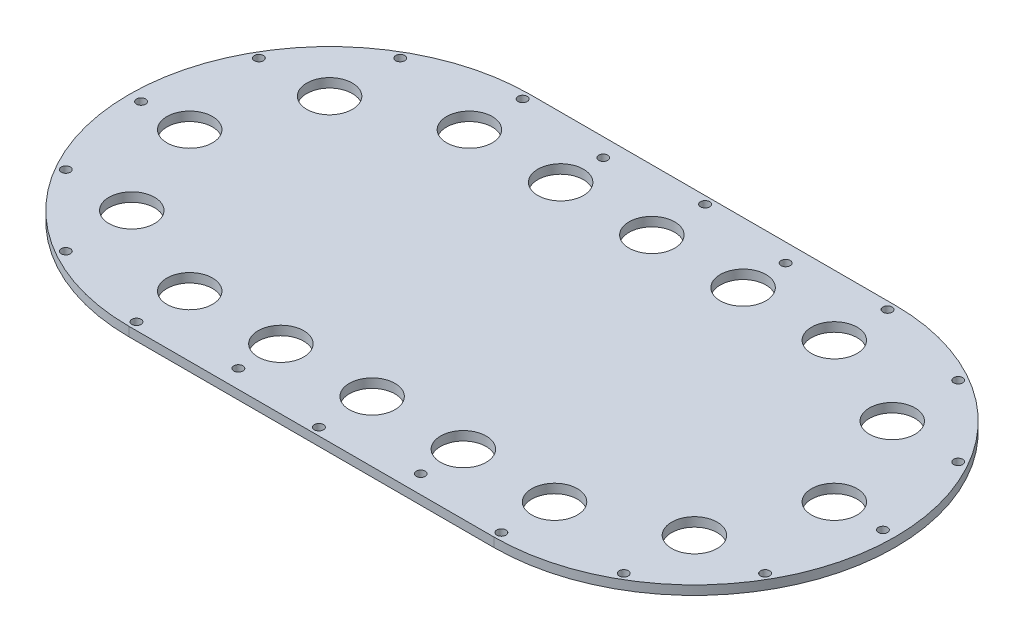
from build123d import *

# Parameters (mm, degrees)
SKETCH_1_R          = 1.5
EXTRUDE_2_DEPTH     = 3
CUT_EXTRUDE_1_DEPTH = 10
SKETCH_4_R          = 7.5
CUT_EXTRUDE_2_DEPTH = 10
SKETCH_5_R          = 1.5
CUT_EXTRUDE_3_DEPTH = 10


with BuildPart() as part:
    # 草图1 → 凸台-拉伸2 (new body)
    with BuildSketch(Plane(origin=(0, 0, 0), x_dir=(1, 0, 0), z_dir=(0, 1, 0))):
        with BuildLine():
            Line((-60, 70), (60, 70))
            ThreePointArc((60, 70), (130, 0), (60, -70))
            Line((60, -70), (-60, -70))
            ThreePointArc((-60, -70), (-130, 0), (-60, 70))
        make_face()
        with Locations((-122, 0)):
            Circle(SKETCH_1_R, mode=Mode.SUBTRACT)
        with Locations((122, 0)):
            Circle(SKETCH_1_R, mode=Mode.SUBTRACT)
        with Locations((-30, 60)):
            Circle(SKETCH_1_R, mode=Mode.SUBTRACT)
        with Locations((30, 60)):
            Circle(SKETCH_1_R, mode=Mode.SUBTRACT)
        with Locations((30, -60)):
            Circle(SKETCH_1_R, mode=Mode.SUBTRACT)
        with Locations((-30, -60)):
            Circle(SKETCH_1_R, mode=Mode.SUBTRACT)
    extrude(amount=EXTRUDE_2_DEPTH)

    # 草图3 → 切除-拉伸1 (cut)
    with BuildSketch(Plane(origin=(0, 3, 0), x_dir=(1, 0, 0), z_dir=(0, 1, 0))):
        with BuildLine():
            Line((-60, -70), (60, -70))
            ThreePointArc((60, -70), (130, 0), (60, 70))
            Line((60, 70), (-60, 70))
            ThreePointArc((-60, 70), (-130, 0), (-60, -70))
        make_face()
        with BuildLine():
            Line((-60, -66), (60, -66))
            ThreePointArc((60, -66), (126, 0), (60, 66))
            Line((60, 66), (-60, 66))
            ThreePointArc((-60, 66), (-126, 0), (-60, -66))
        make_face(mode=Mode.SUBTRACT)
    extrude(amount=-CUT_EXTRUDE_1_DEPTH, mode=Mode.SUBTRACT)

    # 草图4 → 切除-拉伸2 (cut)
    with BuildSketch(Plane(origin=(0, 3, 0), x_dir=(1, 0, 0), z_dir=(0, 1, 0))):
        with Locations((-106, 0)):
            Circle(SKETCH_4_R)
        with Locations((106, 0)):
            Circle(SKETCH_4_R)
        with Locations((0, 46)):
            Circle(SKETCH_4_R)
        with Locations((0, -46)):
            Circle(SKETCH_4_R)
        with Locations((-60, -46)):
            Circle(SKETCH_4_R)
        with Locations((60, -46)):
            Circle(SKETCH_4_R)
        with Locations((30, -46)):
            Circle(SKETCH_4_R)
        with Locations((-30, -46)):
            Circle(SKETCH_4_R)
        with Locations((-92.526911935, -32.526911935)):
            Circle(SKETCH_4_R)
        with Locations((60, 46)):
            Circle(SKETCH_4_R)
        with Locations((30, 46)):
            Circle(SKETCH_4_R)
        with Locations((-92.526911935, 32.526911935)):
            Circle(SKETCH_4_R)
        with Locations((-30, 46)):
            Circle(SKETCH_4_R)
        with Locations((-60, 46)):
            Circle(SKETCH_4_R)
        with Locations((92.526911935, -32.526911935)):
            Circle(SKETCH_4_R)
        with Locations((92.526911935, 32.526911935)):
            Circle(SKETCH_4_R)
    extrude(amount=-CUT_EXTRUDE_2_DEPTH, mode=Mode.SUBTRACT)

    # 草图5 → 切除-拉伸3 (cut)
    with BuildSketch(Plane(origin=(0, 3, 0), x_dir=(1, 0, 0), z_dir=(0, 1, 0))):
        with Locations((-60, 63.5)):
            Circle(SKETCH_5_R)
        with Locations((114.99261314, 31.75)):
            Circle(SKETCH_5_R)
        with Locations((0, 63.5)):
            Circle(SKETCH_5_R)
        with Locations((60, 63.5)):
            Circle(SKETCH_5_R)
        with Locations((91.75, 54.99261314)):
            Circle(SKETCH_5_R)
        with Locations((91.75, -54.99261314)):
            Circle(SKETCH_5_R)
        with Locations((114.99261314, -31.75)):
            Circle(SKETCH_5_R)
        with Locations((-91.75, -54.99261314)):
            Circle(SKETCH_5_R)
        with Locations((-114.99261314, -31.75)):
            Circle(SKETCH_5_R)
        with Locations((-91.75, 54.99261314)):
            Circle(SKETCH_5_R)
        with Locations((-114.99261314, 31.75)):
            Circle(SKETCH_5_R)
        with Locations((60, -63.5)):
            Circle(SKETCH_5_R)
        with Locations((0, -63.5)):
            Circle(SKETCH_5_R)
        with Locations((-60, -63.5)):
            Circle(SKETCH_5_R)
    extrude(amount=-CUT_EXTRUDE_3_DEPTH, mode=Mode.SUBTRACT)


solid = part.part
